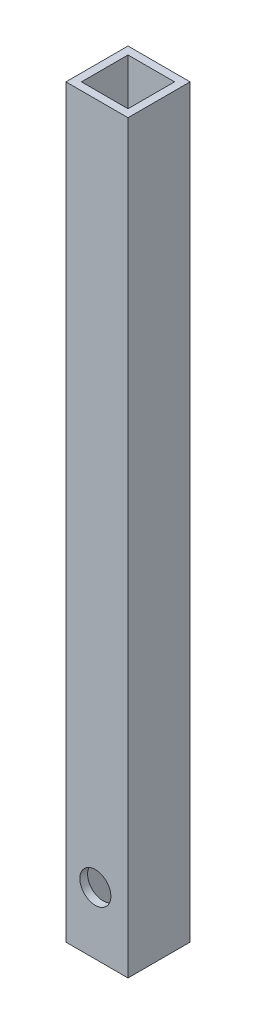
from build123d import *

# Parameters (mm, degrees)
SKETCH1_W           = 12.7
SKETCH1_H           = 12.7
SKETCH1_W_2         = 9.525
SKETCH1_H_2         = 9.525
BOSS_EXTRUDE1_DEPTH = 152.4
SKETCH2_R           = 3.175
CUT_EXTRUDE1_DEPTH  = 13.7


with BuildPart() as part:
    # Sketch1 → Boss-Extrude1 (new body)
    with BuildSketch(Plane(origin=(0, 0, 0), x_dir=(1, 0, 0), z_dir=(0, 1, 0))):
        with Locations((6.35, 6.35)):
            Rectangle(SKETCH1_W, SKETCH1_H)
        with Locations((6.35, 6.35)):
            Rectangle(SKETCH1_W_2, SKETCH1_H_2, mode=Mode.SUBTRACT)
    extrude(amount=BOSS_EXTRUDE1_DEPTH)

    # Sketch2 → Cut-Extrude1 (cut, through all)
    with BuildSketch(Plane(origin=(0, 0, -12.7), x_dir=(-1, 0, 0), z_dir=(0, 0, -1))):
        with Locations((-6.02234, 12.7)):
            Circle(SKETCH2_R)
    extrude(amount=-CUT_EXTRUDE1_DEPTH, mode=Mode.SUBTRACT)


solid = part.part
